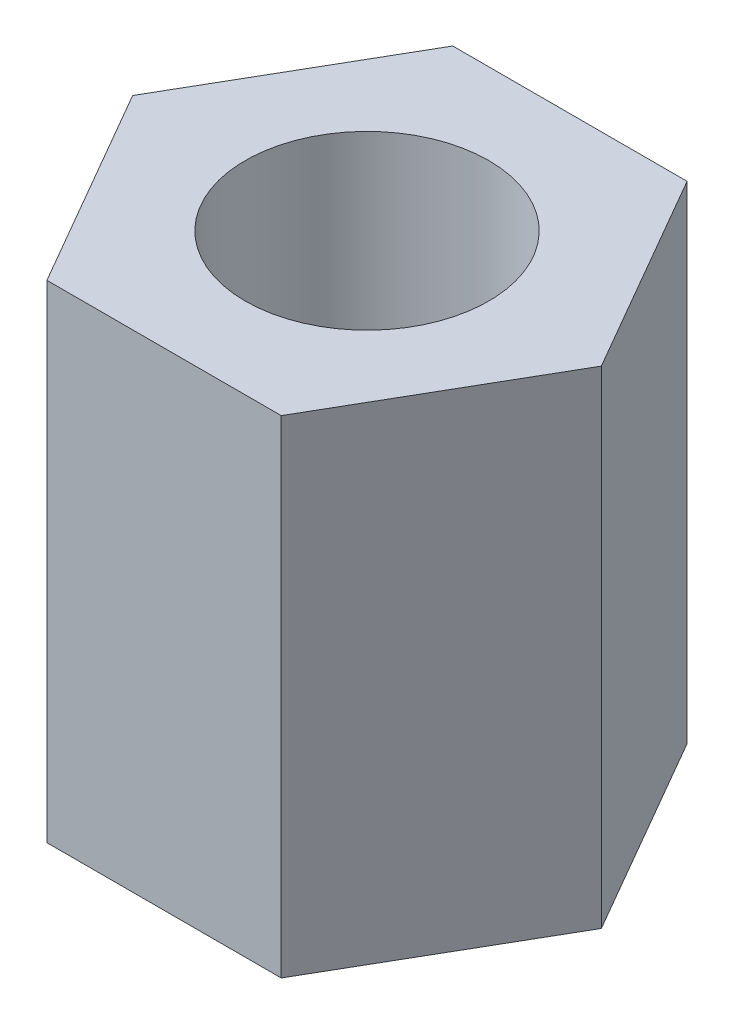
from build123d import *

# Parameters (mm, degrees)
CROQUIS1_R              = 1.5
SALIENTE_EXTRUIR1_DEPTH = 3


with BuildPart() as part:
    # Croquis1 → Saliente-Extruir1 (new body, symmetric)
    with BuildSketch(Plane(origin=(0, 0, 0), x_dir=(1, 0, 0), z_dir=(0, 1, 0))):
        Polygon((1.443375673, -2.5), (2.886751346, 0), (1.443375673, 2.5), (-1.443375673, 2.5), (-2.886751346, 0), (-1.443375673, -2.5), align=None)
        Circle(CROQUIS1_R, mode=Mode.SUBTRACT)
    extrude(amount=SALIENTE_EXTRUIR1_DEPTH, both=True)


solid = part.part
